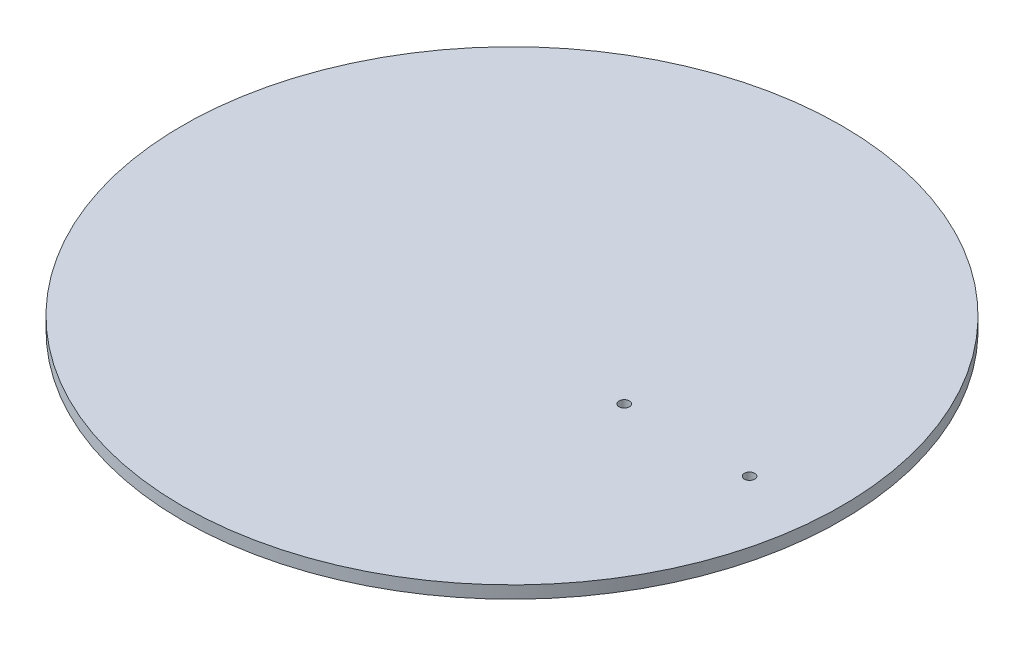
from build123d import *

# Parameters (mm, degrees)
RECORD_R             = 67.31
RECORD_R_2           = 1.054294776
RECORD_EXTRUDE_DEPTH = 2.54


with BuildPart() as part:
    # Record → Record Extrude (new body)
    with BuildSketch(Plane(origin=(0, 0, 0), x_dir=(1, 0, 0), z_dir=(0, 1, 0))):
        with Locations((13.743289035, -70.841587708)):
            Circle(RECORD_R)
        with Locations((66.372058646, -74.952013208)):
            Circle(RECORD_R_2, mode=Mode.SUBTRACT)
        with Locations((40.779568941, -74.952013208)):
            Circle(RECORD_R_2, mode=Mode.SUBTRACT)
    extrude(amount=RECORD_EXTRUDE_DEPTH)


solid = part.part
